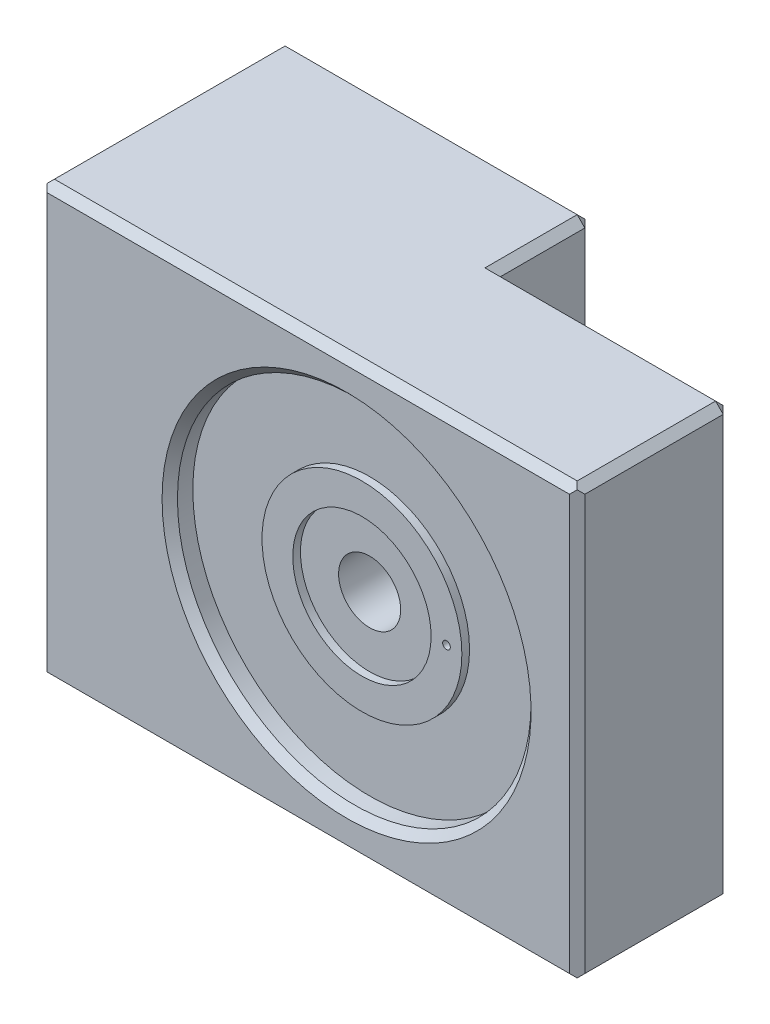
from build123d import *

# Parameters (mm, degrees)
SKETCH1_W               = 35
SKETCH1_H               = 28
BOSS_EXTRUDE1_DEPTH     = 16
SKETCH2_R               = 11.5
CUT_EXTRUDE1_DEPTH      = 1.5
SKETCH3_R               = 2.0193
CUT_EXTRUDE2_DEPTH      = 7
SKETCH4_R               = 4.2164
CUT_EXTRUDE3_DEPTH      = 13.318
CUT_EXTRUDE4_REACH      = 32.366
CUT_EXTRUDE4_END_RADIUS = 2.0193
SKETCH5_R               = 1.2446
SKETCH6_R               = 6.5
SKETCH6_R_2             = 4.5
BOSS_EXTRUDE2_DEPTH     = 0.5
SKETCH7_R               = 0.5
CUT_EXTRUDE5_DEPTH      = 9
SKETCH15_W              = 15
SKETCH15_H              = 28
CUT_EXTRUDE9_DEPTH      = 6
SKETCH16_R              = 1.5875
SKETCH16_R_2            = 0.25
BOSS_EXTRUDE4_DEPTH     = 3
SKETCH17_R              = 0.515994608
SKETCH17_R_2            = 0.25
BOSS_EXTRUDE5_DEPTH     = 9
CHAMFER5_SIZE           = 0.5
CHAMFER6_SIZE           = 0.2
CHAMFER7_SIZE           = 0.5


with BuildPart() as part:
    # Sketch1 → Boss-Extrude1 (new body)
    with BuildSketch(Plane.XY):
        Rectangle(SKETCH1_W, SKETCH1_H)
    extrude(amount=BOSS_EXTRUDE1_DEPTH)

    # Sketch2 → Cut-Extrude1 (cut)
    with BuildSketch(Plane.XY.offset(16)):
        with Locations((2.5, 0)):
            Circle(SKETCH2_R)
    extrude(amount=-CUT_EXTRUDE1_DEPTH, mode=Mode.SUBTRACT)

    # Sketch3 → Cut-Extrude2 (cut)
    with BuildSketch(Plane.XY.offset(14.5)):
        with Locations((2.5, 0)):
            Circle(SKETCH3_R)
    extrude(amount=-CUT_EXTRUDE2_DEPTH, mode=Mode.SUBTRACT)

    # Sketch4 → Cut-Extrude3 (cut)
    with BuildSketch(Plane.ZY.offset(17.5)):
        with Locations((8, 0)):
            Circle(SKETCH4_R)
    extrude(amount=-CUT_EXTRUDE3_DEPTH, mode=Mode.SUBTRACT)

    # Cut-Extrude4: up to this cylinder (the profile starts outside it)
    cut_extrude4_end = Plane(origin=(2.5, 0, 8), z_dir=(0, 0, 1)) * Cylinder(CUT_EXTRUDE4_END_RADIUS, 69.7706, mode=Mode.PRIVATE)
    # Sketch5 → Cut-Extrude4 (cut, up to the surface)
    with BuildSketch(Plane.ZY.offset(4.182), mode=Mode.PRIVATE) as cut_extrude4_sk1:
        with Locations((8, 0)):
            Circle(SKETCH5_R)
    cut_extrude4_tool1 = extrude(cut_extrude4_sk1.sketch, amount=-CUT_EXTRUDE4_REACH, mode=Mode.PRIVATE) - cut_extrude4_end
    add(cut_extrude4_tool1.solids().sort_by_distance((-4.182, 0, 8))[0], mode=Mode.SUBTRACT)

    # Sketch6 → Boss-Extrude2 (add)
    with BuildSketch(Plane.XY.offset(14.5)):
        with Locations((2.5, 0)):
            Circle(SKETCH6_R)
        with Locations((2.5, 0)):
            Circle(SKETCH6_R_2, mode=Mode.SUBTRACT)
    extrude(amount=BOSS_EXTRUDE2_DEPTH)

    # Sketch7 → Cut-Extrude5 (cut)
    with BuildSketch(Plane.XY.offset(15)):
        with Locations((8, 0)):
            Circle(SKETCH7_R)
    extrude(amount=-CUT_EXTRUDE5_DEPTH, mode=Mode.SUBTRACT)

    # Sketch15 → Cut-Extrude9 (cut)
    with BuildSketch(Plane(origin=(0, 0, 0), x_dir=(-1, 0, 0), z_dir=(0, 0, -1))):
        with Locations((-10, 0)):
            Rectangle(SKETCH15_W, SKETCH15_H)
    extrude(amount=-CUT_EXTRUDE9_DEPTH, mode=Mode.SUBTRACT)

    # Sketch16 → Boss-Extrude4 (add)
    with BuildSketch(Plane(origin=(0, 0, 6), x_dir=(-1, 0, 0), z_dir=(0, 0, -1))):
        with Locations((-8, 0)):
            Circle(SKETCH16_R)
        with Locations((-8, 0)):
            Circle(SKETCH16_R_2, mode=Mode.SUBTRACT)
    extrude(amount=BOSS_EXTRUDE4_DEPTH)

    # Sketch17 → Boss-Extrude5 (add)
    with BuildSketch(Plane.XY.offset(6)):
        with Locations((8, 0)):
            Circle(SKETCH17_R)
        with Locations((8, 0)):
            Circle(SKETCH17_R_2, mode=Mode.SUBTRACT)
    extrude(amount=BOSS_EXTRUDE5_DEPTH)

    # Chamfer5
    chamfer5_edges = [part.edges().sort_by_distance(p)[0] for p in [
        (0, -14, 16),
        (-9, 0, 16),
        (17.5, 0, 16),
        (0, 14, 16),
        (-17.5, 0, 16),
    ]]
    chamfer(chamfer5_edges, length=CHAMFER5_SIZE)

    # Chamfer6
    chamfer6_edges = [part.edges().sort_by_distance(p)[0] for p in [
        (9.5875, 0, 3),
    ]]
    chamfer(chamfer6_edges, length=CHAMFER6_SIZE)

    # Chamfer7
    chamfer7_edges = [part.edges().sort_by_distance(p)[0] for p in [
        (-7.5, 14, 0),
        (-7.5, -14, 0),
        (10, -14, 6),
        (2.5, -14, 3),
        (17.5, 0, 6),
        (10, 14, 6),
        (2.5, 14, 3),
        (2.5, 0, 0),
        (-17.5, 0, 0),
        (17.5, 14, 10.75),
        (17.5, -14, 10.75),
        (-17.5, 14, 7.75),
        (-17.5, -14, 7.75),
    ]]
    chamfer(chamfer7_edges, length=CHAMFER7_SIZE)


solid = part.part
